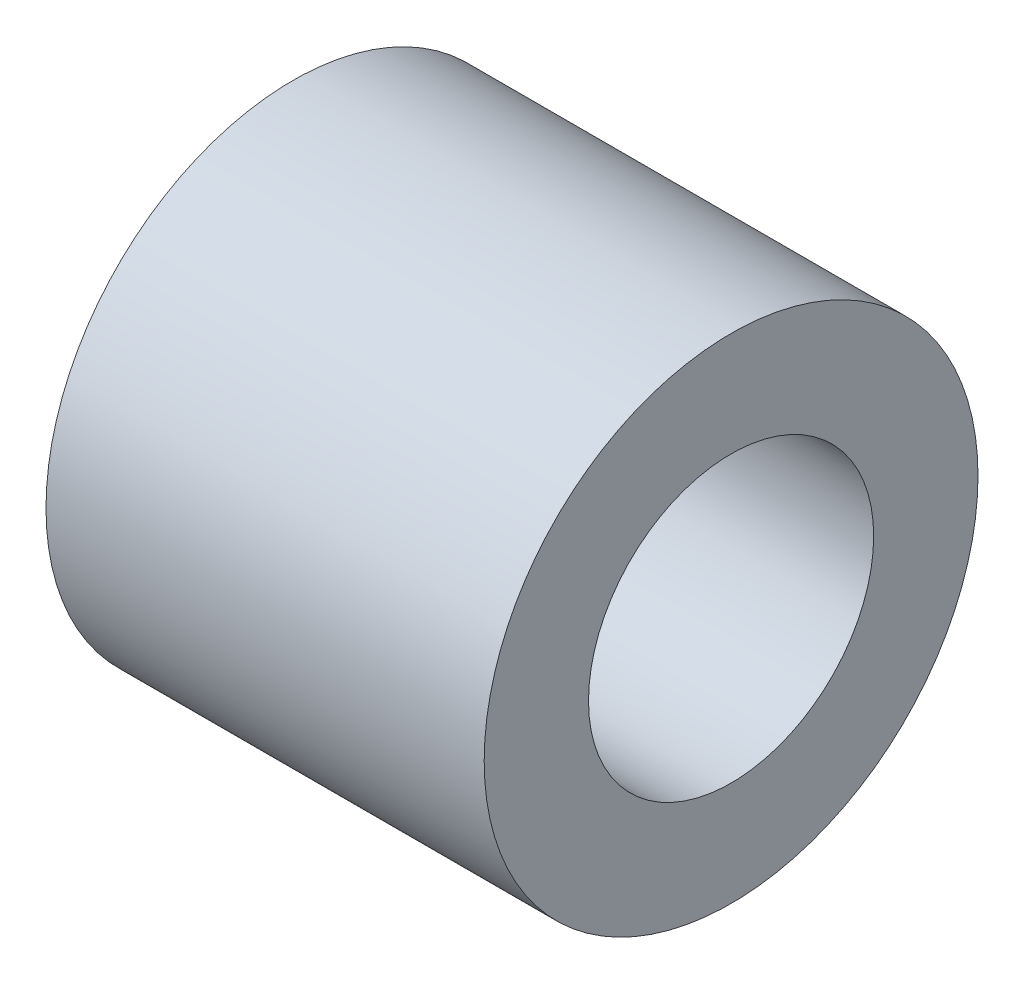
from build123d import *

# Parameters (mm, degrees)
SKETCH1_W = 12.6
SKETCH1_H = 3


with BuildPart() as part:
    # Sketch1 → Revolve1 (revolve)
    with BuildSketch(Plane(origin=(0, 0, 0), x_dir=(1, 0, 0), z_dir=(0, 1, 0))):
        with Locations((6.3, -5.6)):
            Rectangle(SKETCH1_W, SKETCH1_H)
    revolve(axis=Axis((0, 0, 0), (1, 0, 0)))


solid = part.part
